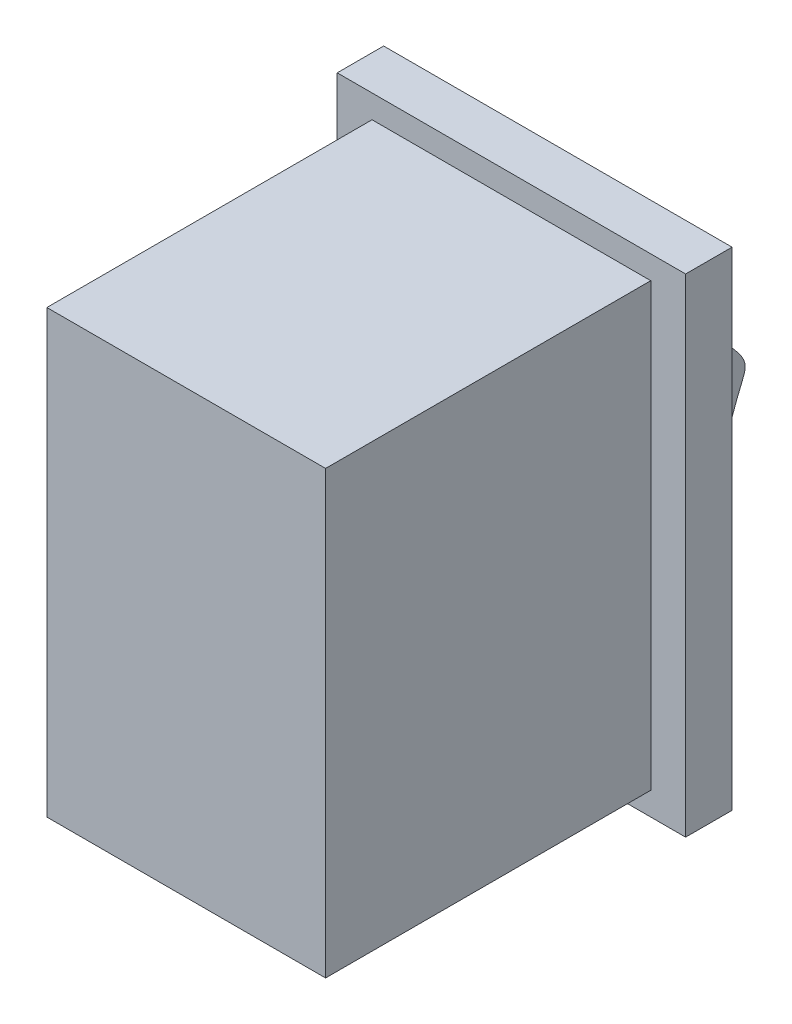
from build123d import *

# Parameters (mm, degrees)
SKETCH1_W           = 12
SKETCH1_H           = 19
BOSS_EXTRUDE1_DEPTH = 14
SKETCH2_W           = 15
SKETCH2_H           = 21
BOSS_EXTRUDE2_DEPTH = 2
BOSS_EXTRUDE3_START = 1
BOSS_EXTRUDE3_DEPTH = 10


with BuildPart() as part:
    # Sketch1 → Boss-Extrude1 (new body)
    with BuildSketch(Plane.XY):
        with Locations((6, 9.5)):
            Rectangle(SKETCH1_W, SKETCH1_H)
    extrude(amount=BOSS_EXTRUDE1_DEPTH)

    # Sketch2 → Boss-Extrude2 (add)
    with BuildSketch(Plane.XY):
        with Locations((6, 9.5)):
            Rectangle(SKETCH2_W, SKETCH2_H)
    extrude(amount=-BOSS_EXTRUDE2_DEPTH)

    # Sketch3 → Boss-Extrude3 (add)
    with BuildSketch(Plane(origin=(0, 0, 0), x_dir=(0, 0, -1), z_dir=(1, 0, 0)).offset(BOSS_EXTRUDE3_START)):
        with BuildLine():
            Line((2, 16.5), (2, 2.5))
            add(Edge.make_bspline(
                [(2, 2.5), (2, 3.412146721), (5.218686286, 14.113667424), (5.401393948, 12.681295538), (2, 16.5)],
                knots=[0, 0, 0, 0, 0.602336799, 1, 1, 1, 1], degree=3))
        make_face()
    extrude(amount=BOSS_EXTRUDE3_DEPTH)


solid = part.part
